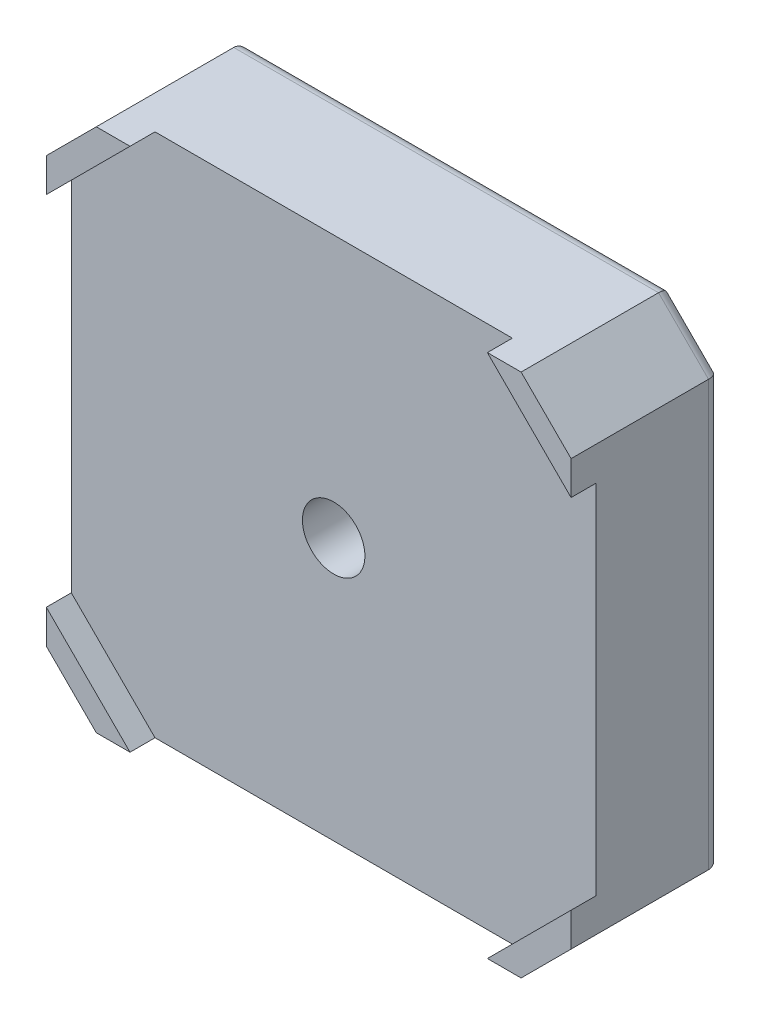
from build123d import *

# Parameters (mm, degrees)
BOSS_EXTRUDE1_DEPTH            = 12
CUT_EXTRUDE1_DEPTH             = 2
SKETCH3_R                      = 11
BOSS_EXTRUDE2_DEPTH            = 2
SKETCH4_R                      = 5.5
CUT_EXTRUDE2_DEPTH             = 7
SKETCH5_R                      = 2.5
CUT_EXTRUDE3_DEPTH             = 8
FILLET1_R                      = 1
FILLET2_R                      = 0.5
M3X0_5_TAPPED_HOLE1_AT_2_COUNT = 2
M3X0_5_TAPPED_HOLE1_AT_2_PITCH = 31
M3X0_5_TAPPED_HOLE1_AT_3_COUNT = 2
M3X0_5_TAPPED_HOLE1_AT_3_PITCH = 21.920310217
LPATTERN1_COUNT                = 2
LPATTERN1_PITCH                = 31
FILLET4_R                      = 0.25


with BuildPart() as part:
    # Sketch1 → Boss-Extrude1 (new body)
    with BuildSketch(Plane.XY):
        Polygon((-21, 17), (-17, 21), (17, 21), (21, 17), (21, -17), (17, -21), (-17, -21), (-21, -17), align=None)
    extrude(amount=BOSS_EXTRUDE1_DEPTH)

    # Sketch2 → Cut-Extrude1 (cut)
    with BuildSketch(Plane.XY.offset(12)):
        Polygon((-21.15, 14.15), (-14.15, 21.15), (14.15, 21.15), (21.15, 14.15), (21.15, -14.15), (14.15, -21.15), (-14.15, -21.15), (-21.15, -14.15), align=None)
    extrude(amount=-CUT_EXTRUDE1_DEPTH, mode=Mode.SUBTRACT)

    # Sketch3 → Boss-Extrude2 (add)
    with BuildSketch(Plane(origin=(0, 0, 0), x_dir=(-1, 0, 0), z_dir=(0, 0, -1))):
        Circle(SKETCH3_R)
    extrude(amount=BOSS_EXTRUDE2_DEPTH)

    # Sketch4 → Cut-Extrude2 (cut)
    with BuildSketch(Plane(origin=(0, 0, -2), x_dir=(-1, 0, 0), z_dir=(0, 0, -1))):
        Circle(SKETCH4_R)
    extrude(amount=-CUT_EXTRUDE2_DEPTH, mode=Mode.SUBTRACT)

    # Sketch5 → Cut-Extrude3 (cut, through all)
    with BuildSketch(Plane(origin=(0, 0, 5), x_dir=(-1, 0, 0), z_dir=(0, 0, -1))):
        Circle(SKETCH5_R)
    extrude(amount=-CUT_EXTRUDE3_DEPTH, mode=Mode.SUBTRACT)

    # Fillet1
    fillet1_edges = [part.edges().sort_by_distance(p)[0] for p in [
        (19, -19, 0),
        (0, -21, 0),
        (-19, -19, 0),
        (-21, 0, 0),
        (-19, 19, 0),
        (0, 21, 0),
        (19, 19, 0),
        (21, 0, 0),
    ]]
    fillet(fillet1_edges, radius=FILLET1_R)

    # Fillet2
    fillet2_edges = [part.edges().sort_by_distance(p)[0] for p in [
        (11, 0, -2),
        (5.5, 0, 5),
        (5.5, 0, -2),
    ]]
    fillet(fillet2_edges, radius=FILLET2_R)

    # Sketch8 → M3x0.5 Tapped Hole1 (revolve, cut)
    with BuildSketch(Plane(origin=(15.5, 15.5, 0), x_dir=(0, 1, 0), z_dir=(1, 0, 0))):
        Polygon((0, 0), (0, 5.251075774), (1.25, 4.5), (1.25, 0), align=None)
    m3x0_5_tapped_hole1 = revolve(axis=Axis((15.5, 15.5, -6.35), (0, 0, 1)), mode=Mode.SUBTRACT)

    # M3x0.5 Tapped Hole1 at 2: M3x0.5 Tapped Hole1 ×2
    with Locations(*[(-i * M3X0_5_TAPPED_HOLE1_AT_2_PITCH, 0, 0) for i in range(1, M3X0_5_TAPPED_HOLE1_AT_2_COUNT)]):
        add(m3x0_5_tapped_hole1, mode=Mode.SUBTRACT)

    # M3x0.5 Tapped Hole1 at 3: M3x0.5 Tapped Hole1 ×2
    with Locations(*[Vector(-0.707106781, -0.707106781, 0) * (i * M3X0_5_TAPPED_HOLE1_AT_3_PITCH) for i in range(1, M3X0_5_TAPPED_HOLE1_AT_3_COUNT)]):
        add(m3x0_5_tapped_hole1, mode=Mode.SUBTRACT)

    # LPattern1: M3x0.5 Tapped Hole1 ×2
    with Locations(*[(0, -i * LPATTERN1_PITCH, 0) for i in range(1, LPATTERN1_COUNT)]):
        add(m3x0_5_tapped_hole1, mode=Mode.SUBTRACT)

    # LPattern1 copy 1 sketch → LPattern1 copy 1 (revolve, cut)
    with BuildSketch(Plane(origin=(-15.5, -15.5, 0), x_dir=(0, 1, 0), z_dir=(1, 0, 0))):
        Polygon((0, 0), (0, 5.251075774), (1.25, 4.5), (1.25, 0), align=None)
    revolve(axis=Axis((-15.5, -15.5, -6.35), (0, 0, 1)), mode=Mode.SUBTRACT)

    # LPattern1 copy 2 sketch → LPattern1 copy 2 (revolve, cut)
    with BuildSketch(Plane(origin=(0, -31, 0), x_dir=(0, 1, 0), z_dir=(1, 0, 0))):
        Polygon((0, 0), (0, 5.251075774), (1.25, 4.5), (1.25, 0), align=None)
    revolve(axis=Axis((0, -31, -6.35), (0, 0, 1)), mode=Mode.SUBTRACT)

    # Fillet4
    fillet4_edges = [part.edges().sort_by_distance(p)[0] for p in [
        (-15.5, 14.25, 0),
        (15.5, 14.25, 0),
        (-15.5, -16.75, 0),
        (15.5, -16.75, 0),
    ]]
    fillet(fillet4_edges, radius=FILLET4_R)


solid = part.part
